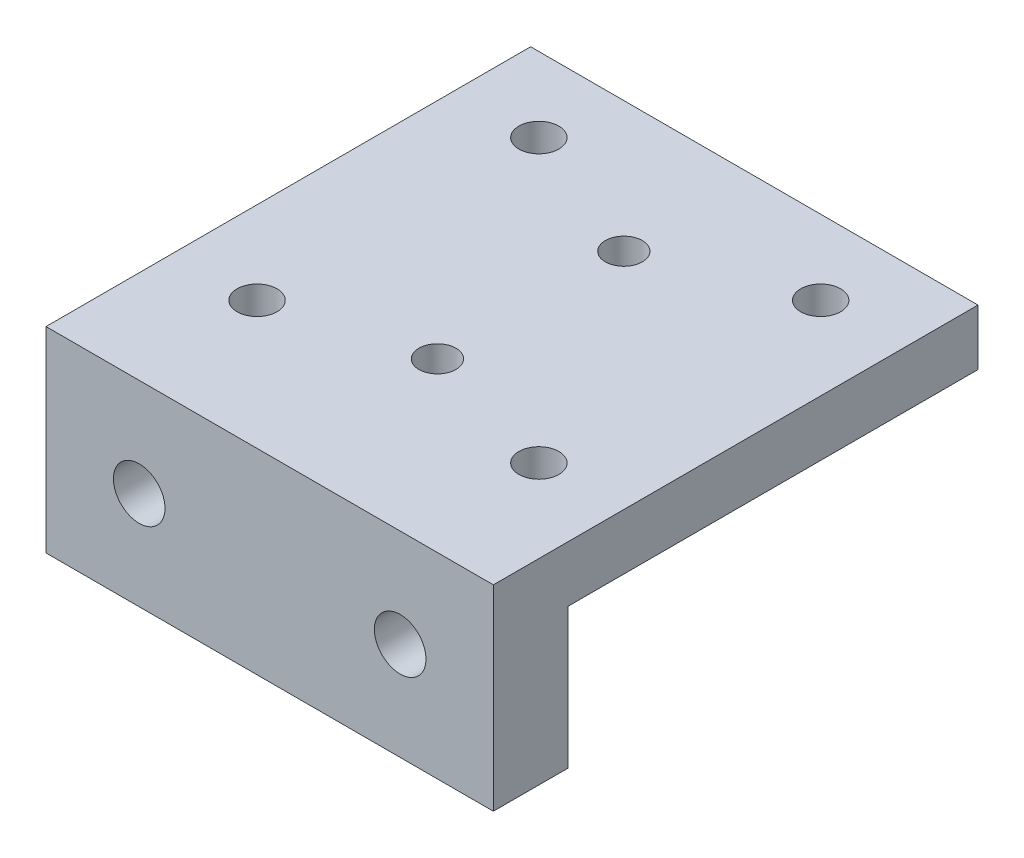
from build123d import *

# Parameters (mm, degrees)
BOSS_EXTRUDE1_DEPTH                = 19.05
M3_CLEARANCE_HOLE1_D               = 3.4
TAPPED_HOLE_FOR_M3X0_5_HELICOIL1_D = 3.15
TAPPED_HOLE_FOR_8_32_HELICOIL1_D   = 4.3942


with BuildPart() as part:
    # Sketch1 → Boss-Extrude1 (new body, symmetric)
    with BuildSketch(Plane(origin=(0, 0, 0), x_dir=(0, 0, -1), z_dir=(1, 0, 0))):
        Polygon((20.6375, 0), (-20.6375, 0), (-20.6375, -16.7005), (-14.2875, -16.7005), (-14.2875, -4.7625), (20.6375, -4.7625), align=None)
    extrude(amount=BOSS_EXTRUDE1_DEPTH, both=True)

    # M3 Clearance Hole1 (through all)
    with Locations(Plane(origin=(0, -4.7625, 0), x_dir=(-1, 0, 0), z_dir=(0, -1, 0))):
        with Locations((-12, 14.2875), (12, 14.2875), (12, -9.7125), (-12, -9.7125)):
            Hole(M3_CLEARANCE_HOLE1_D / 2)

    # Tapped Hole for M3x0.5 Helicoil1 (through all)
    with Locations(Plane(origin=(0, -4.7625, 0), x_dir=(-1, 0, 0), z_dir=(0, -1, 0))):
        with Locations((0, -6.35), (0, 9.525)):
            Hole(TAPPED_HOLE_FOR_M3X0_5_HELICOIL1_D / 2)

    # Tapped Hole for #8-32 Helicoil1 (through all)
    with Locations(Plane.XY.offset(20.6375)):
        with Locations((-11.1125, -8.35025), (11.1125, -8.35025)):
            Hole(TAPPED_HOLE_FOR_8_32_HELICOIL1_D / 2)


solid = part.part
